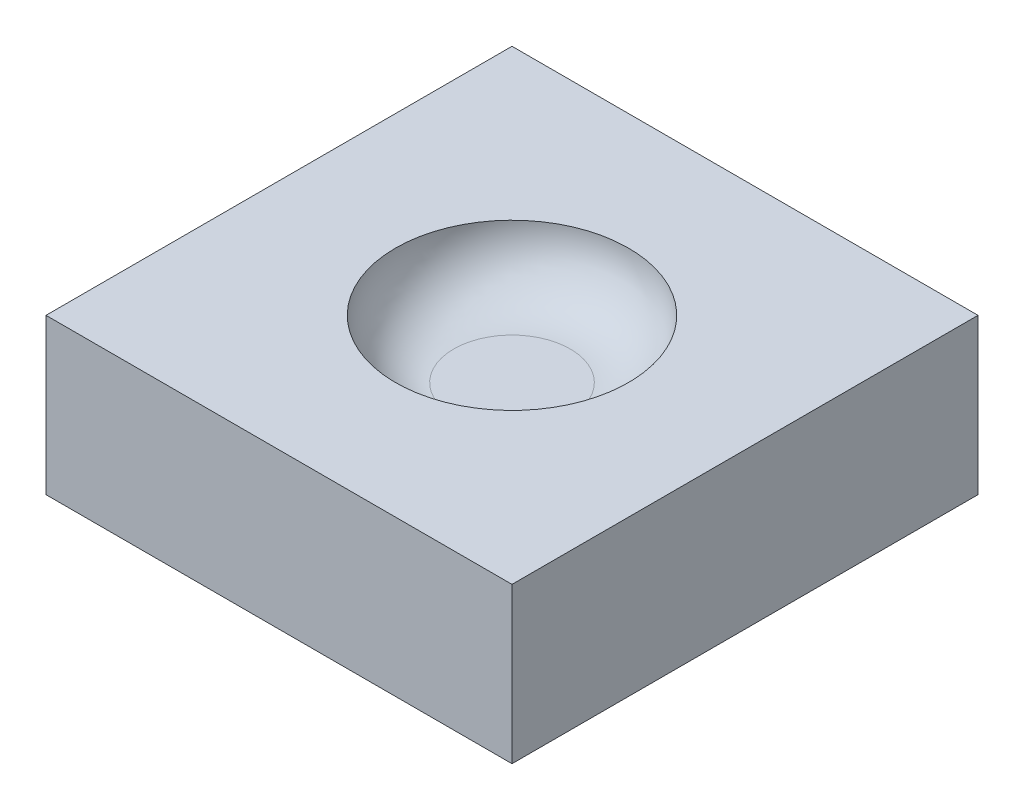
from build123d import *

# Parameters (mm, degrees)
SKETCH2_W           = 152.4
SKETCH2_H           = 152.4
BOSS_EXTRUDE1_DEPTH = 50.8


with BuildPart() as part:
    # Sketch2 → Boss-Extrude1 (new body)
    with BuildSketch(Plane(origin=(0, 0, 0), x_dir=(1, 0, 0), z_dir=(0, 1, 0))):
        Rectangle(SKETCH2_W, SKETCH2_H)
    extrude(amount=BOSS_EXTRUDE1_DEPTH)

    # Sketch3 → Cut-Revolve1 (revolve, cut)
    with BuildSketch(Plane.XY):
        with BuildLine():
            Line((-19.05, 31.75), (0, 31.75))
            Line((0, 31.75), (0, 50.8))
            Line((0, 50.8), (-38.1, 50.8))
            ThreePointArc((-38.1, 50.8), (-32.520384182, 37.329615818), (-19.05, 31.75))
        make_face()
    revolve(axis=Axis((0, 50.8, 0), (0, -1, 0)), mode=Mode.SUBTRACT)


solid = part.part
